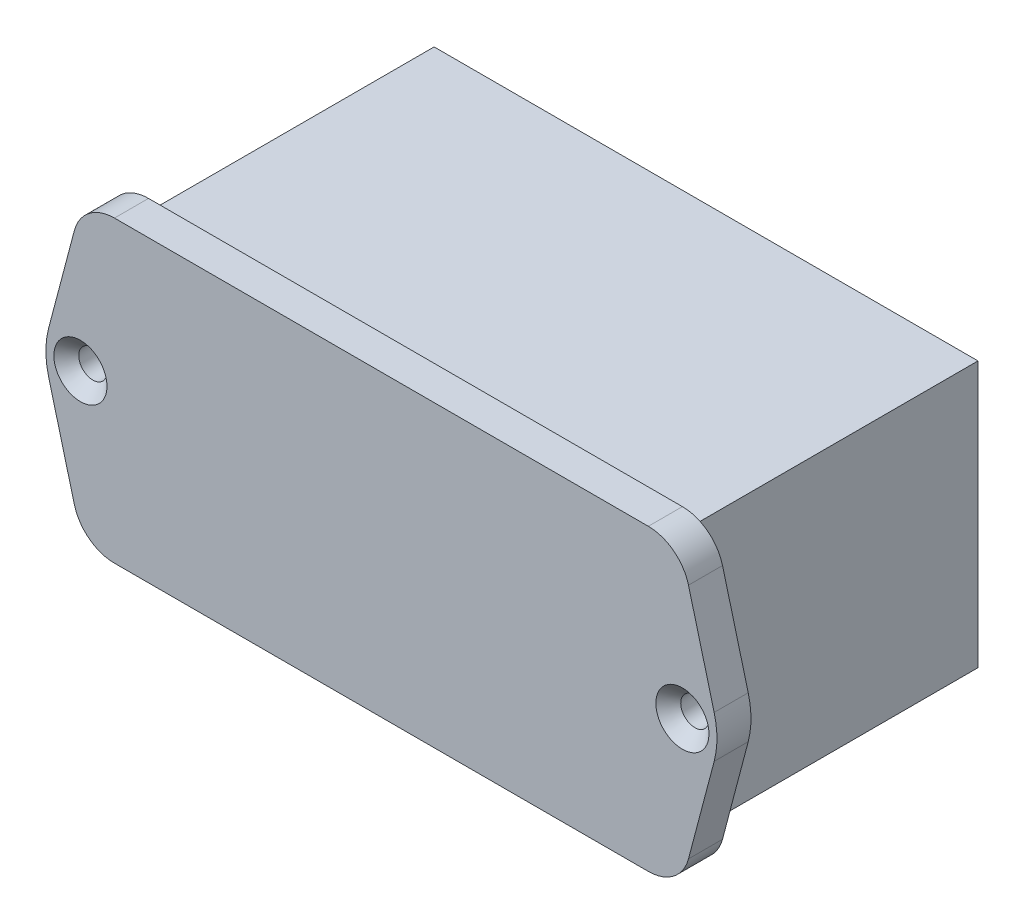
from build123d import *

# Parameters (mm, degrees)
SCHIZZO1_R                   = 1.7
ESTRUSIONE_ESTRUSIONE1_DEPTH = 4.1
SCHIZZO2_W                   = 65.5
SCHIZZO2_H                   = 32
SCHIZZO2_W_2                 = 63.5
SCHIZZO2_H_2                 = 30
ESTRUSIONE_SOTTILE1_DEPTH    = 35
SMUSSO1_SIZE                 = 1.5


with BuildPart() as part:
    # Schizzo1 → Estrusione-Estrusione1 (new body)
    with BuildSketch(Plane.XY):
        with BuildLine():
            Line((32.14828078, 18), (-32.14828078, 18))
            ThreePointArc((-32.14828078, 18), (-35.199603729, 16.960988294), (-36.982782572, 14.275771306))
            Line((-36.982782572, 14.275771306), (-40.076676255, 2.551542612))
            ThreePointArc((-40.076676255, 2.551542612), (-40.407672672, 0), (-40.076676255, -2.551542612))
            Line((-40.076676255, -2.551542612), (-36.982782572, -14.275771306))
            ThreePointArc((-36.982782572, -14.275771306), (-35.199603729, -16.960988294), (-32.14828078, -18))
            Line((-32.14828078, -18), (32.14828078, -18))
            ThreePointArc((32.14828078, -18), (35.199603729, -16.960988294), (36.982782572, -14.275771306))
            Line((36.982782572, -14.275771306), (40.076676255, -2.551542612))
            ThreePointArc((40.076676255, -2.551542612), (40.407672672, 0), (40.076676255, 2.551542612))
            Line((40.076676255, 2.551542612), (36.982782572, 14.275771306))
            ThreePointArc((36.982782572, 14.275771306), (35.199603729, 16.960988294), (32.14828078, 18))
        make_face()
        with Locations((-36.25, 0)):
            Circle(SCHIZZO1_R, mode=Mode.SUBTRACT)
        with Locations((36.25, 0)):
            Circle(SCHIZZO1_R, mode=Mode.SUBTRACT)
    extrude(amount=-ESTRUSIONE_ESTRUSIONE1_DEPTH)

    # Schizzo2 → Estrusione-Sottile1 (add)
    with BuildSketch(Plane(origin=(0, 0, -4.1), x_dir=(-1, 0, 0), z_dir=(0, 0, -1))):
        Rectangle(SCHIZZO2_W, SCHIZZO2_H)
        Rectangle(SCHIZZO2_W_2, SCHIZZO2_H_2, mode=Mode.SUBTRACT)
    extrude(amount=ESTRUSIONE_SOTTILE1_DEPTH)

    # Smusso1
    smusso1_edges = [part.edges().sort_by_distance(p)[0] for p in [
        (-37.95, 0, 0),
        (34.55, 0, 0),
    ]]
    chamfer(smusso1_edges, length=SMUSSO1_SIZE)


solid = part.part
